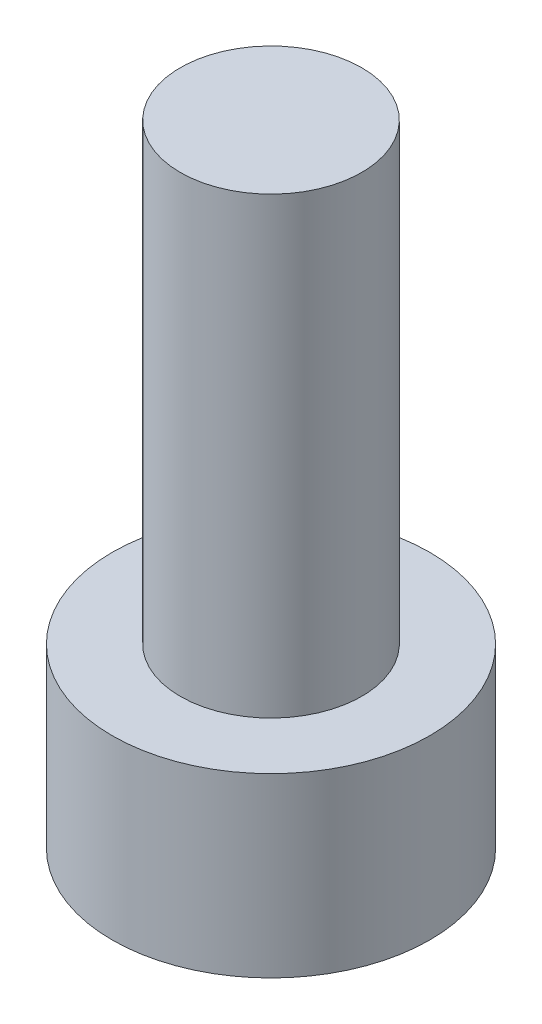
from build123d import *

# Parameters (mm, degrees)
SKETCH_1_R          = 3.5
EXTRUDE_1_DEPTH     = 3.9
SKETCH_2_R          = 2
EXTRUDE_2_DEPTH     = 10
CUT_EXTRUDE_1_DEPTH = 2.4


with BuildPart() as part:
    # 草图1 → 凸台-拉伸1 (new body)
    with BuildSketch(Plane(origin=(0, 0, 0), x_dir=(1, 0, 0), z_dir=(0, 1, 0))):
        Circle(SKETCH_1_R)
    extrude(amount=EXTRUDE_1_DEPTH)

    # 草图2 → 凸台-拉伸2 (add)
    with BuildSketch(Plane(origin=(0, 3.9, 0), x_dir=(1, 0, 0), z_dir=(0, 1, 0))):
        Circle(SKETCH_2_R)
    extrude(amount=EXTRUDE_2_DEPTH)

    # 草图3 → 切除-拉伸1 (cut)
    with BuildSketch(Plane.XZ):
        Polygon((1.725, 0), (0.8625, 1.493893822), (-0.8625, 1.493893822), (-1.725, 0), (-0.8625, -1.493893822), (0.8625, -1.493893822), align=None)
    extrude(amount=-CUT_EXTRUDE_1_DEPTH, mode=Mode.SUBTRACT)


solid = part.part
